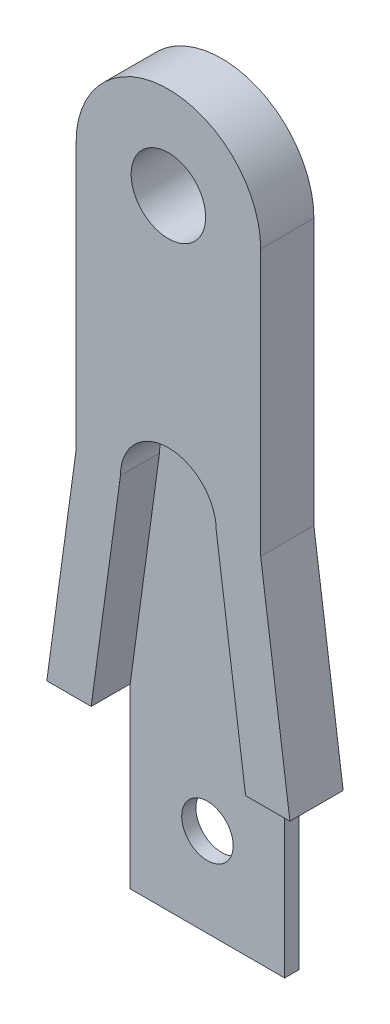
from build123d import *

# Parameters (mm, degrees)
BOSS_EXTRUDE1_DEPTH        = 3
CUT_EXTRUDE1_DEPTH         = 2.2
SKETCH3_W                  = 8.7
SKETCH3_H                  = 0.8
BOSS_EXTRUDE2_DEPTH        = 10
F_3_7_3_7_DIAMETER_HOLE1_D = 4.2
F_2_9_2_9_DIAMETER_HOLE1_D = 2.9


with BuildPart() as part:
    # Sketch1 → Boss-Extrude1 (new body)
    with BuildSketch(Plane(origin=(0, 0, 4.056081063), x_dir=(-1, 0, 0), z_dir=(0, 0, -1))):
        with BuildLine():
            Line((-1.941684048, 16.511778169), (-3.591684048, 4.411778169))
            Line((-3.591684048, 4.411778169), (10.108315952, 4.411778169))
            Line((10.108315952, 4.411778169), (8.458315952, 16.511778169))
            Line((8.458315952, 16.511778169), (8.458315952, 31.511778169))
            ThreePointArc((8.458315952, 31.511778169), (3.258315952, 36.711778169), (-1.941684048, 31.511778169))
            Line((-1.941684048, 31.511778169), (-1.941684048, 16.511778169))
        make_face()
    extrude(amount=-BOSS_EXTRUDE1_DEPTH)

    # Sketch2 → Cut-Extrude1 (cut)
    with BuildSketch(Plane.XY.offset(7.056081063)):
        with BuildLine():
            Line((1.091684048, 4.411778169), (-0.558315952, 16.511778169))
            ThreePointArc((-0.558315952, 16.511778169), (-3.258315952, 19.211778169), (-5.958315952, 16.511778169))
            Line((-5.958315952, 16.511778169), (-7.608315952, 4.411778169))
            Line((-7.608315952, 4.411778169), (1.091684048, 4.411778169))
        make_face()
    extrude(amount=-CUT_EXTRUDE1_DEPTH, mode=Mode.SUBTRACT)

    # Sketch3 → Boss-Extrude2 (add)
    with BuildSketch(Plane.XZ.offset(-4.411778169)):
        with Locations((-3.258315952, 4.456081063)):
            Rectangle(SKETCH3_W, SKETCH3_H)
    extrude(amount=BOSS_EXTRUDE2_DEPTH)

    # Ø3.7 (3.7) Diameter Hole1 (through all)
    with Locations(Plane(origin=(0, 0, 4.056081063), x_dir=(-1, 0, 0), z_dir=(0, 0, -1))):
        with Locations((3.258315952, 31.511778169)):
            Hole(F_3_7_3_7_DIAMETER_HOLE1_D / 2)

    # Ø2.9 (2.9) Diameter Hole1 (through all)
    with Locations(Plane(origin=(0, 0, 4.056081063), x_dir=(-1, 0, 0), z_dir=(0, 0, -1))):
        with Locations((3.258315952, -0.588221831)):
            Hole(F_2_9_2_9_DIAMETER_HOLE1_D / 2)


solid = part.part
